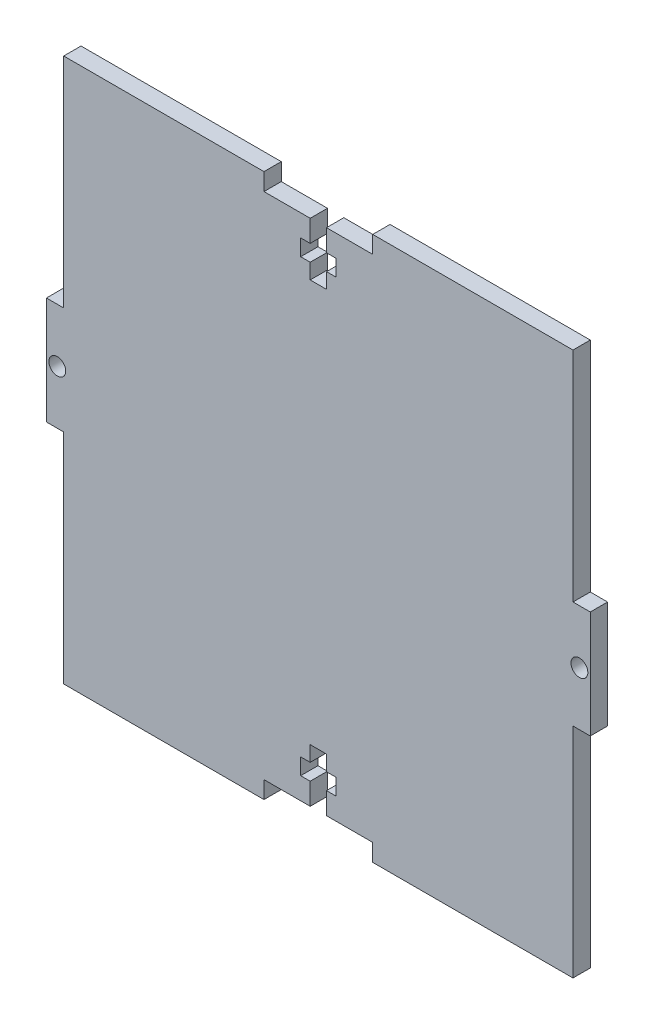
from build123d import *

# Parameters (mm, degrees)
SKETCH1_W           = 100
SKETCH1_H           = 100
BOSS_EXTRUDE2_DEPTH = 3.18
SKETCH2_R           = 1.55
SKETCH2_W           = 3.18
SKETCH2_H           = 40.125
CUT_EXTRUDE1_DEPTH  = 4.18


with BuildPart() as part:
    # Sketch1 → Boss-Extrude2 (new body)
    with BuildSketch(Plane.XY):
        Rectangle(SKETCH1_W, SKETCH1_H)
    extrude(amount=BOSS_EXTRUDE2_DEPTH)

    # Sketch2 → Cut-Extrude1 (cut, through all)
    with BuildSketch(Plane.XY.offset(3.18)):
        with Locations((-48, 0)):
            Circle(SKETCH2_R)
        Polygon((-10, 50), (-10, 46.82), (-1.5, 46.82), (-1.5, 42.82), (-3.25, 42.82), (-3.25, 39.82), (-1.5, 39.82), (-1.5, 37), (1.5, 37), (1.5, 39.82), (3.25, 39.82), (3.25, 42.82), (1.5, 42.82), (1.5, 46.82), (10, 46.82), (10, 50), align=None)
        with Locations((-48.41, 29.9375)):
            Rectangle(SKETCH2_W, SKETCH2_H)
        with Locations((-48.41, -29.9375)):
            Rectangle(SKETCH2_W, SKETCH2_H)
    cut_extrude1 = extrude(amount=-CUT_EXTRUDE1_DEPTH, mode=Mode.SUBTRACT)

    # Mirror1: Cut-Extrude1 across plane
    add(cut_extrude1.mirror(Plane.ZX), mode=Mode.SUBTRACT)

    # Mirror3: Cut-Extrude1 across plane
    add(cut_extrude1.mirror(Plane(origin=(0, 0, 0), x_dir=(0, 0, 1), z_dir=(1, 0, 0))), mode=Mode.SUBTRACT)


solid = part.part
